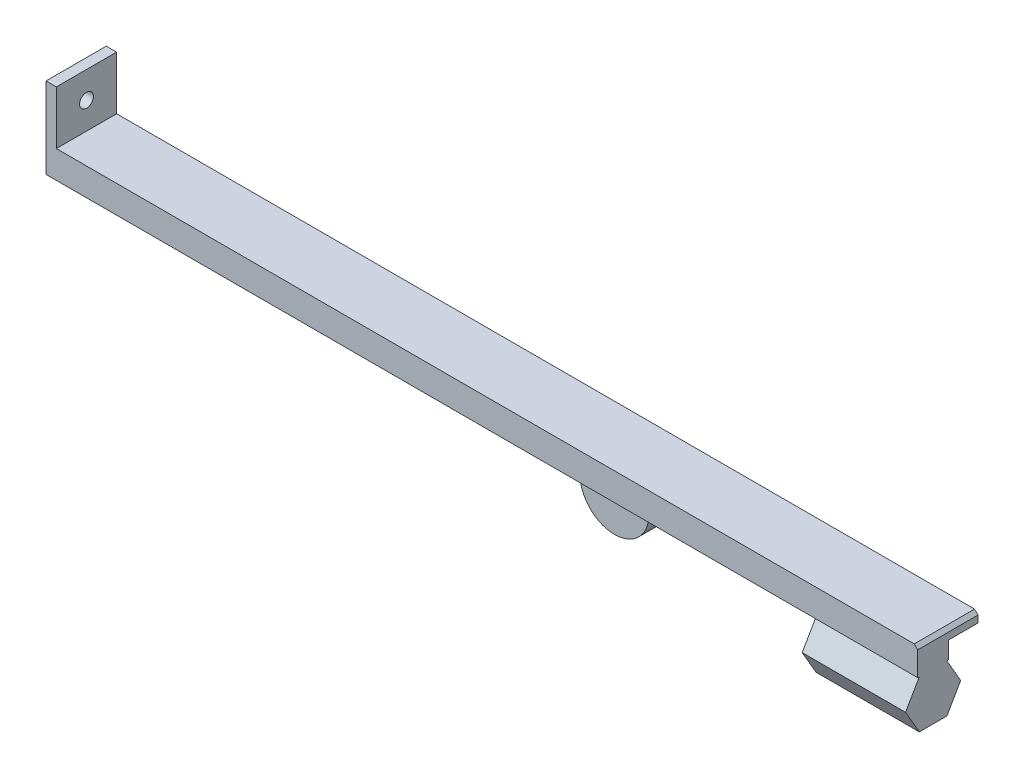
from build123d import *

# Parameters (mm, degrees)
SKETCH1_W           = 250
SKETCH1_H           = 5
SKETCH1_W_2         = 143
SKETCH1_W_3         = 87
BOSS_EXTRUDE1_DEPTH = 17.5
SKETCH1_3_W         = 250
SKETCH1_3_H         = 5
CUT_EXTRUDE1_DEPTH  = 8.5
SKETCH2_R           = 2
CUT_EXTRUDE2_DEPTH  = 8.5
SKETCH1_5_R         = 2
BOSS_EXTRUDE2_DEPTH = 8.5
BOSS_EXTRUDE3_DEPTH = 30


with BuildPart() as part:
    # Sketch1 → Boss-Extrude1 (new body)
    with BuildSketch(Plane.XY):
        with Locations((125, 2.5)):
            Rectangle(SKETCH1_W, SKETCH1_H)
        Polygon((249, 8), (250, 7), (250, 5), (0, 5), (0, 8), align=None)
        Polygon((0, 23.5), (0, 8), (0, 5), (0, 0), (-3, 0), (-3, 23.5), align=None)
        with Locations((71.5, 2.5)):
            Rectangle(SKETCH1_W_2, SKETCH1_H)
        with Locations((206.5, 2.5)):
            Rectangle(SKETCH1_W_3, SKETCH1_H)
    extrude(amount=BOSS_EXTRUDE1_DEPTH)

    # Sketch1_3 → Cut-Extrude1 (cut)
    with BuildSketch(Plane.XY):
        with Locations((125, 2.5)):
            Rectangle(SKETCH1_3_W, SKETCH1_3_H)
    extrude(amount=CUT_EXTRUDE1_DEPTH, mode=Mode.SUBTRACT)

    # Sketch2 → Cut-Extrude2 (cut)
    with BuildSketch(Plane(origin=(0, 0, 0), x_dir=(0, 0, -1), z_dir=(1, 0, 0))):
        with Locations((-8.75, 15.75)):
            Circle(SKETCH2_R)
    extrude(amount=-CUT_EXTRUDE2_DEPTH, mode=Mode.SUBTRACT)

    # Sketch1_5 → Boss-Extrude2 (add)
    with BuildSketch(Plane.XY):
        with BuildLine():
            Line((163, 5), (143, 5))
            Line((143, 5), (143, -7))
            ThreePointArc((143, -7), (153, -17), (163, -7))
            Line((163, -7), (163, 5))
        make_face()
        with Locations((153, -7)):
            Circle(SKETCH1_5_R, mode=Mode.SUBTRACT)
    extrude(amount=BOSS_EXTRUDE2_DEPTH)

    # Sketch4 → Boss-Extrude3 (add)
    with BuildSketch(Plane(origin=(250, 0, 0), x_dir=(0, 0, -1), z_dir=(1, 0, 0))):
        Polygon((-5.029428908, -6.92820323), (-9.029428908, 0), (-17.029428908, 0), (-21.029428908, -6.92820323), (-17.029428908, -13.856406461), (-9.029428908, -13.856406461), align=None)
    extrude(amount=-BOSS_EXTRUDE3_DEPTH)


solid = part.part
